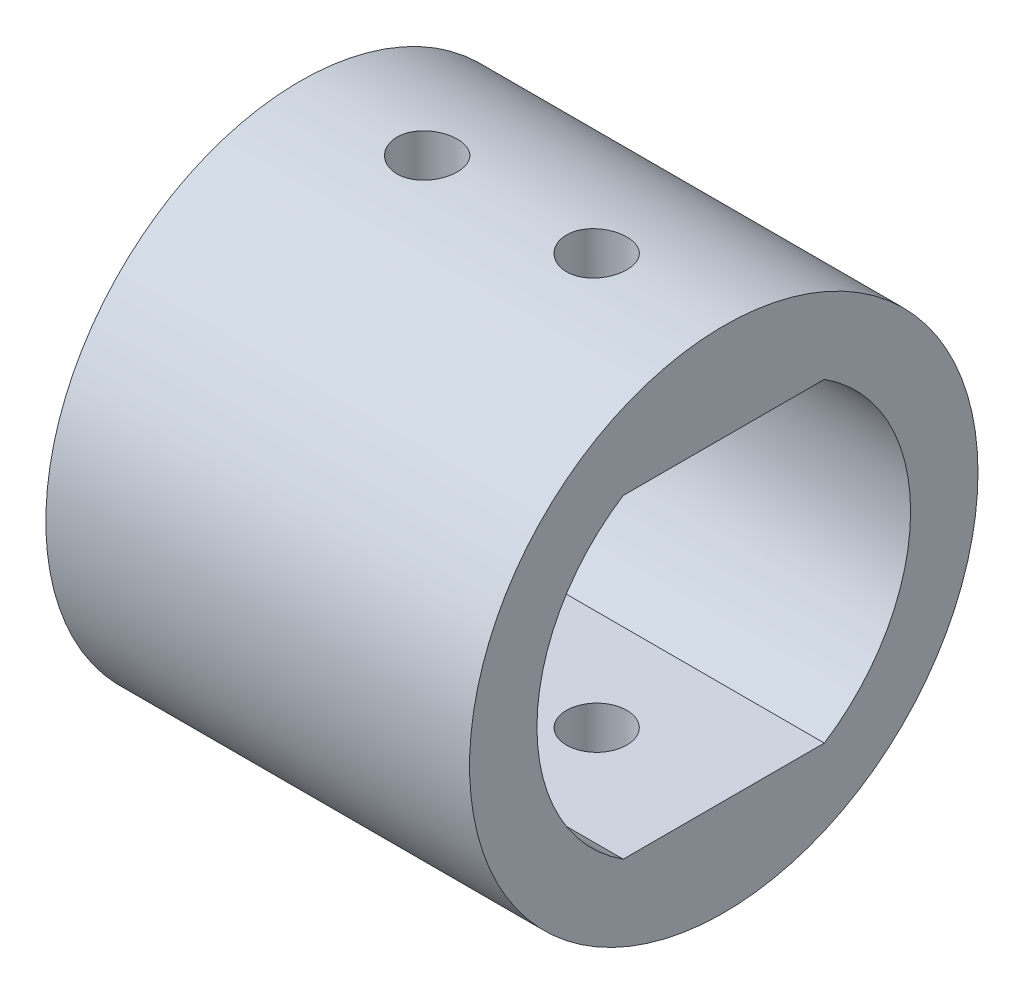
from build123d import *

# Parameters (mm, degrees)
SKETCH1_R               = 9.525
BOSS_EXTRUDE1_DEPTH     = 7.9375
SKETCH2_R               = 1.1303
CUT_EXTRUDE1_DEPTH      = 1
CUT_EXTRUDE1_DEPTH_BACK = 20.05


with BuildPart() as part:
    # Sketch1 → Boss-Extrude1 (new body, symmetric)
    with BuildSketch(Plane(origin=(0, 0, 0), x_dir=(0, 0, -1), z_dir=(1, 0, 0))):
        Circle(SKETCH1_R)
        with BuildLine():
            Line((-3.76696164, 5.9), (3.76696164, 5.9))
            ThreePointArc((3.76696164, 5.9), (7, 0), (3.76696164, -5.9))
            Line((3.76696164, -5.9), (-3.76696164, -5.9))
            ThreePointArc((-3.76696164, -5.9), (-7, 0), (-3.76696164, 5.9))
        make_face(mode=Mode.SUBTRACT)
    extrude(amount=BOSS_EXTRUDE1_DEPTH, both=True)

    # Sketch2 → Cut-Extrude1 (cut, two sides)
    with BuildSketch(Plane(origin=(0, 9.525, 0), x_dir=(1, 0, 0), z_dir=(0, 1, 0))) as cut_extrude1_sk:
        with Locations((-3.175, 0)):
            Circle(SKETCH2_R)
        with Locations((3.175, 0)):
            Circle(SKETCH2_R)
    extrude(amount=CUT_EXTRUDE1_DEPTH, mode=Mode.SUBTRACT)
    extrude(cut_extrude1_sk.sketch, amount=-CUT_EXTRUDE1_DEPTH_BACK, mode=Mode.SUBTRACT)


solid = part.part
